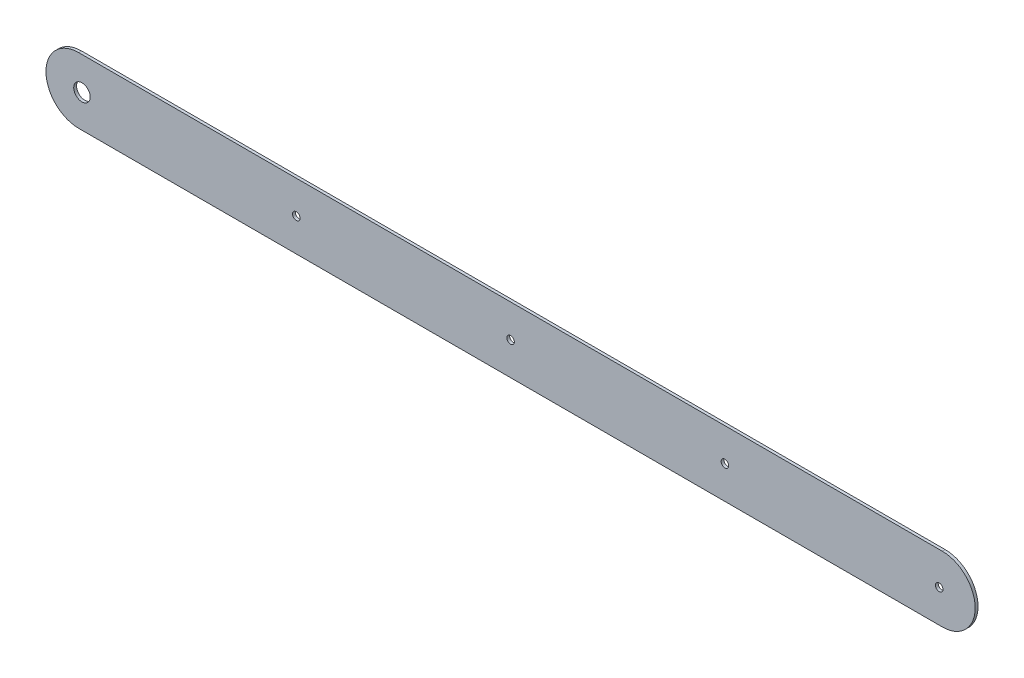
from build123d import *

# Parameters (mm, degrees)
EXTRUDE_THIN1_DEPTH     = 3
BOSS_EXTRUDE1_DEPTH     = 3
CUT_EXTRUDE1_DEPTH      = 987.36983936
CUT_EXTRUDE1_DEPTH_BACK = 987.36983936
SKETCH2_R               = 8
SKETCH2_R_2             = 17.5


with BuildPart() as part:
    # Sketch1 → Extrude-Thin1 (new, symmetric)
    with BuildSketch(Plane.XY):
        with BuildLine():
            Line((914.4, -69.5), (-914.4, -69.5))
            ThreePointArc((-914.4, -69.5), (-983.9, 0), (-914.4, 69.5))
            Line((-914.4, 69.5), (914.4, 69.5))
            ThreePointArc((914.4, 69.5), (983.9, 0), (914.4, -69.5))
        make_face()
        with BuildLine():
            Line((914.4, -63.5), (-914.4, -63.5))
            ThreePointArc((-914.4, -63.5), (-977.9, 0), (-914.4, 63.5))
            Line((-914.4, 63.5), (914.4, 63.5))
            ThreePointArc((914.4, 63.5), (977.9, 0), (914.4, -63.5))
        make_face(mode=Mode.SUBTRACT)
    extrude(amount=EXTRUDE_THIN1_DEPTH, both=True)

    # Sketch1_3 → Boss-Extrude1 (add, symmetric)
    with BuildSketch(Plane.XY):
        with BuildLine():
            Line((-914.4, 63.5), (914.4, 63.5))
            ThreePointArc((914.4, 63.5), (977.9, 0), (914.4, -63.5))
            Line((914.4, -63.5), (-914.4, -63.5))
            ThreePointArc((-914.4, -63.5), (-977.9, 0), (-914.4, 63.5))
        make_face()
    extrude(amount=BOSS_EXTRUDE1_DEPTH, both=True)

    # Sketch2 → Cut-Extrude1 (cut, two sides: drawn at the far end of the back side and taken through both)
    with BuildSketch(Plane.XY.offset(3).offset(-CUT_EXTRUDE1_DEPTH_BACK)):
        Circle(SKETCH2_R)
        with Locations((907.7, 0)):
            Circle(SKETCH2_R)
        with Locations((-907.7, 0)):
            Circle(SKETCH2_R_2)
        with Locations((453.85, 0)):
            Circle(SKETCH2_R)
        with Locations((-453.85, 0)):
            Circle(SKETCH2_R)
    extrude(amount=CUT_EXTRUDE1_DEPTH + CUT_EXTRUDE1_DEPTH_BACK, mode=Mode.SUBTRACT)


solid = part.part
